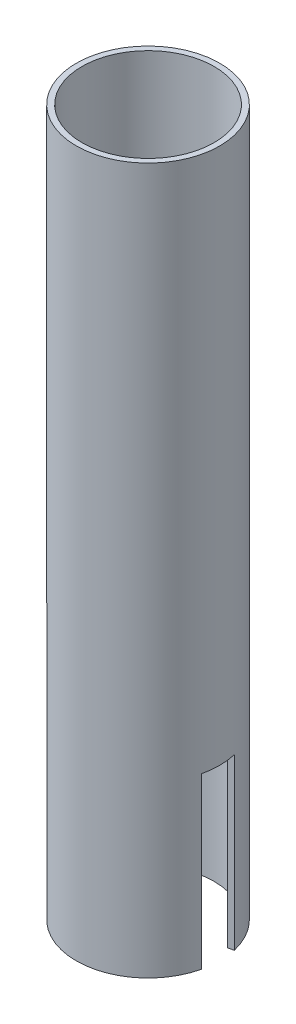
from build123d import *

# Parameters (mm, degrees)
SKETCH1_R           = 25.4
SKETCH1_R_2         = 23.4
BOSS_EXTRUDE1_DEPTH = 125
CUT_EXTRUDE1_DEPTH  = 60


with BuildPart() as part:
    # Sketch1 → Boss-Extrude1 (new body, symmetric)
    with BuildSketch(Plane(origin=(0, 0, 0), x_dir=(1, 0, 0), z_dir=(0, 1, 0))):
        Circle(SKETCH1_R)
        Circle(SKETCH1_R_2, mode=Mode.SUBTRACT)
    extrude(amount=BOSS_EXTRUDE1_DEPTH, both=True)

    # Sketch2 → Cut-Extrude1 (cut)
    with BuildSketch(Plane.XZ.offset(125)):
        with BuildLine():
            Line((-24.719681161, -5.839294762), (-22.773249573, -5.379507773))
            ThreePointArc((-22.773249573, -5.379507773), (-23.4, 0), (-22.773249573, 5.379507773))
            Line((-22.773249573, 5.379507773), (-24.719681161, 5.839294762))
            ThreePointArc((-24.719681161, 5.839294762), (-25.4, 0), (-24.719681161, -5.839294762))
        make_face()
        with BuildLine():
            Line((24.719681161, -5.839294762), (22.773249573, -5.379507773))
            ThreePointArc((22.773249573, -5.379507773), (23.4, 0), (22.773249573, 5.379507773))
            Line((22.773249573, 5.379507773), (24.719681161, 5.839294762))
            ThreePointArc((24.719681161, 5.839294762), (25.4, 0), (24.719681161, -5.839294762))
        make_face()
    extrude(amount=-CUT_EXTRUDE1_DEPTH, mode=Mode.SUBTRACT)


solid = part.part
